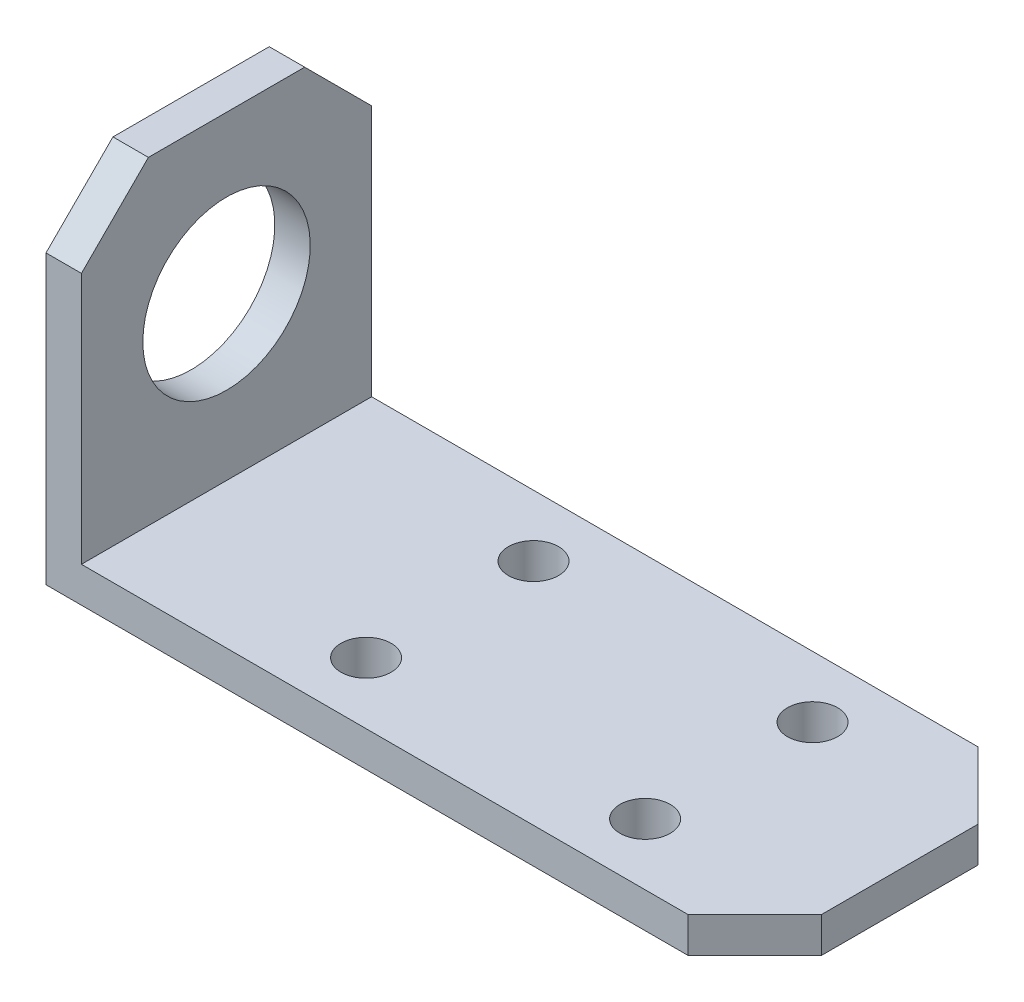
from build123d import *

# Parameters (mm, degrees)
BOSS_EXTRUDE1_DEPTH  = 26
M4_CLEARANCE_HOLE1_D = 4.5
SKETCH5_R            = 7.5
CUT_EXTRUDE1_DEPTH   = 64.5
CHAMFER1_SIZE        = 6


with BuildPart() as part:
    # Sketch1 → Boss-Extrude1 (new body)
    with BuildSketch(Plane.XY):
        Polygon((0, 0), (0, 31.75), (3.175, 31.75), (3.175, 3.175), (63.5, 3.175), (63.5, 0), align=None)
    extrude(amount=BOSS_EXTRUDE1_DEPTH)

    # M4 Clearance Hole1 (through all)
    with Locations(Plane(origin=(0, 3.175, 0), x_dir=(1, 0, 0), z_dir=(0, 1, 0))):
        with Locations((23.175, -20.5), (23.175, -5.5), (48.175, -5.5), (48.175, -20.5)):
            Hole(M4_CLEARANCE_HOLE1_D / 2)

    # Sketch5 → Cut-Extrude1 (cut, through all)
    with BuildSketch(Plane.ZY):
        with Locations((13, 17.675)):
            Circle(SKETCH5_R)
    extrude(amount=-CUT_EXTRUDE1_DEPTH, mode=Mode.SUBTRACT)

    # Chamfer1
    chamfer1_edges = [part.edges().sort_by_distance(p)[0] for p in [
        (1.5875, 31.75, 26),
        (1.5875, 31.75, 0),
        (63.5, 1.5875, 0),
        (63.5, 1.5875, 26),
    ]]
    chamfer(chamfer1_edges, length=CHAMFER1_SIZE)


solid = part.part
